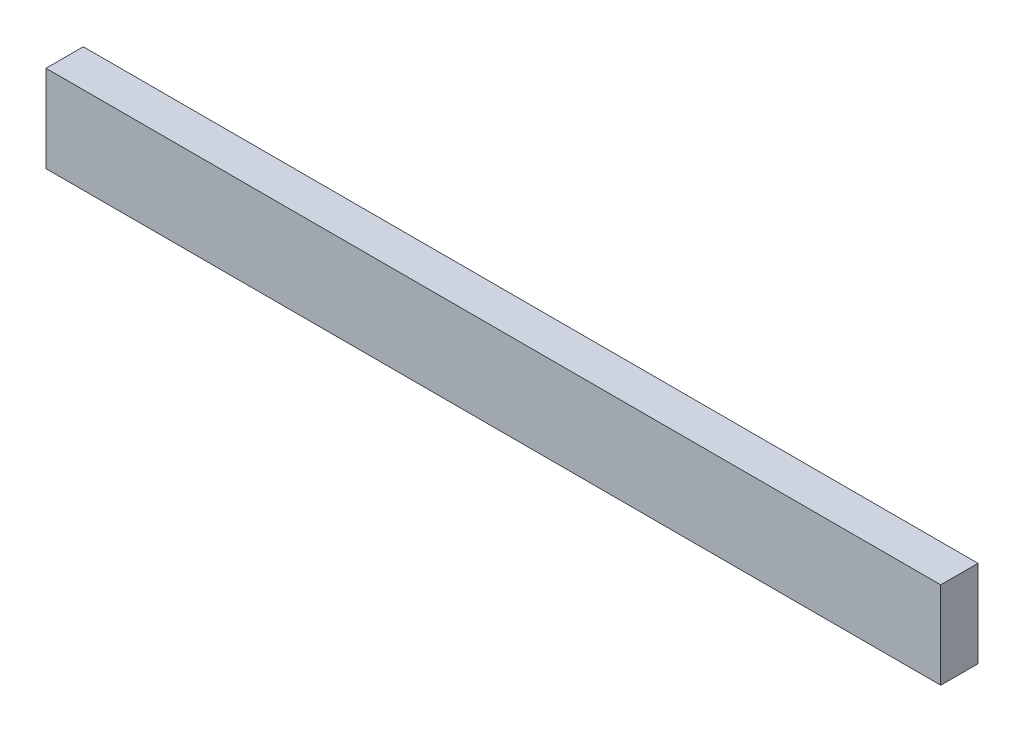
from build123d import *

# Parameters (mm, degrees)
SKETCH1_W           = 38.1
SKETCH1_H           = 88.9
BOSS_EXTRUDE1_DEPTH = 914.4


with BuildPart() as part:
    # Sketch1 → Boss-Extrude1 (new body)
    with BuildSketch(Plane(origin=(0, 0, 0), x_dir=(0, 0, -1), z_dir=(1, 0, 0))):
        Rectangle(SKETCH1_W, SKETCH1_H)
    extrude(amount=BOSS_EXTRUDE1_DEPTH)


solid = part.part
